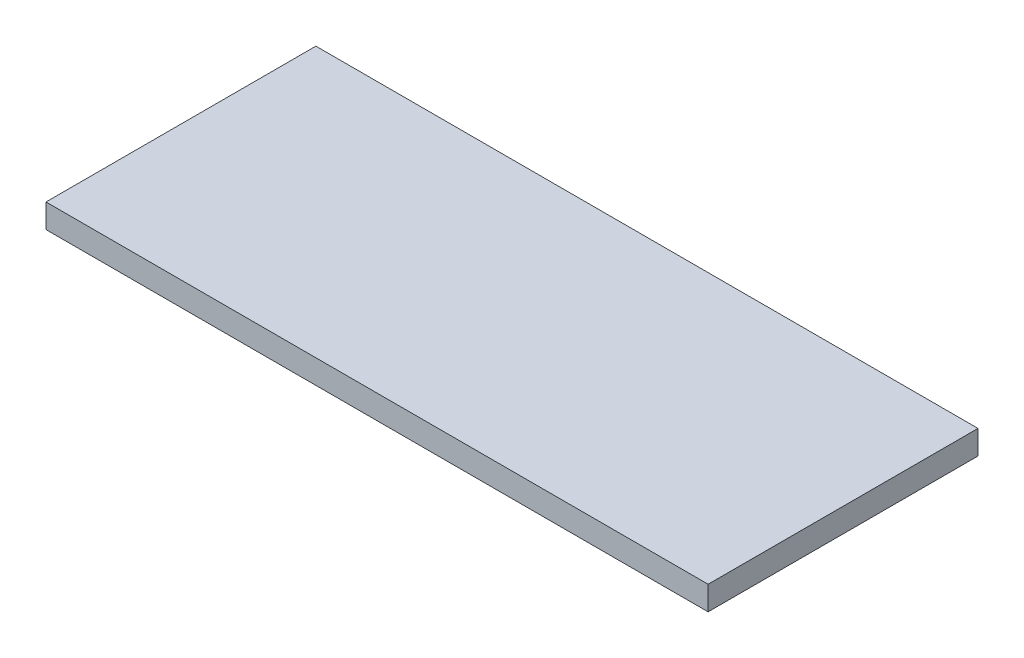
from build123d import *

# Parameters (mm, degrees)
SKETCH_1_W      = 498
SKETCH_1_H      = 203
EXTRUDE_1_DEPTH = 18


with BuildPart() as part:
    # Эскиз1 → Бобышка-Вытянуть1 (new body)
    with BuildSketch(Plane(origin=(0, 0, 0), x_dir=(1, 0, 0), z_dir=(0, 1, 0))):
        Rectangle(SKETCH_1_W, SKETCH_1_H)
    extrude(amount=EXTRUDE_1_DEPTH)


solid = part.part
